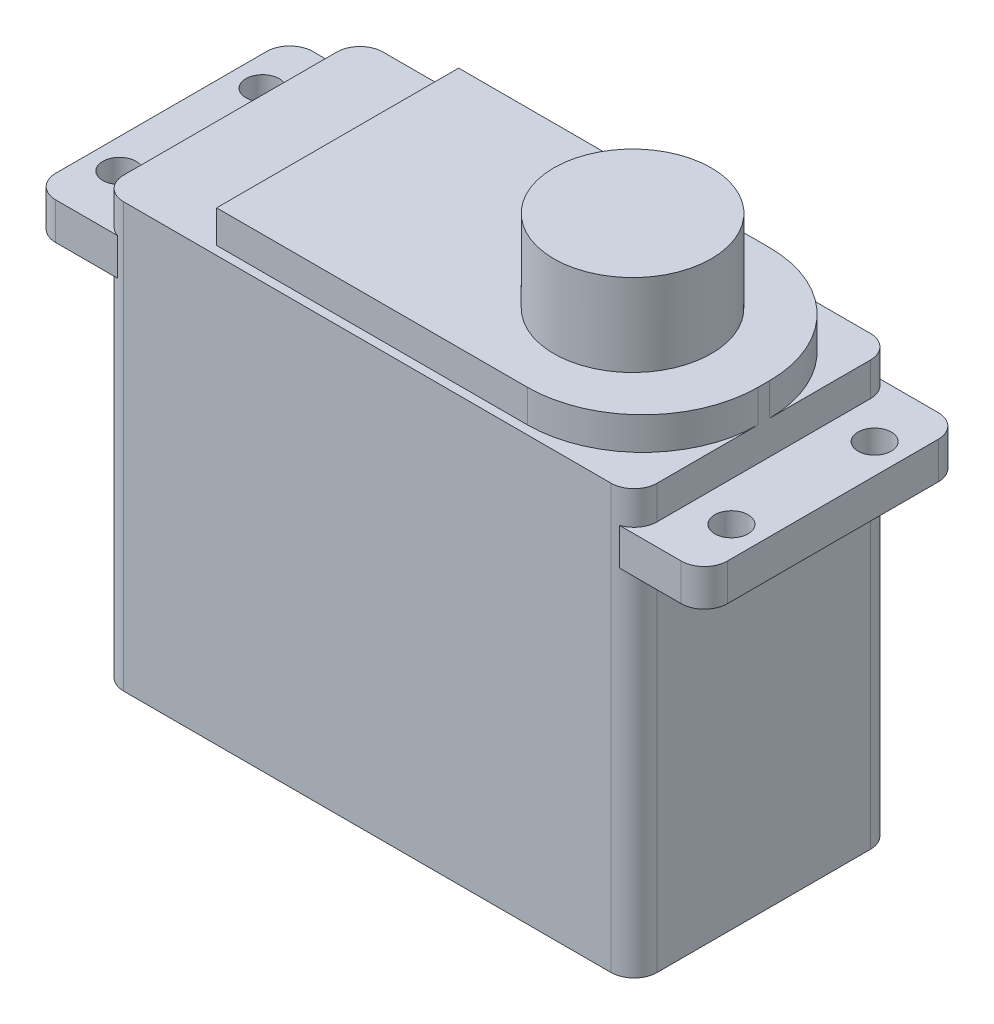
from build123d import *

# Parameters (mm, degrees)
SKETCH1_W           = 58.674
SKETCH1_H           = 28.5242
BOSS_EXTRUDE1_DEPTH = 46.609
SKETCH2_W           = 46.863
SKETCH2_H           = 26.6192
BOSS_EXTRUDE2_DEPTH = 3.5814
FILLET1_R           = 12.7
FILLET2_R           = 2.54
BOSS_EXTRUDE3_START = -7.747
SKETCH3_W           = 73.8632
SKETCH3_H           = 28.2702
BOSS_EXTRUDE3_DEPTH = 4.064
FILLET3_R           = 2.54
SKETCH4_R           = 1.8288
CUT_EXTRUDE1_DEPTH  = 43.926
SKETCH5_R           = 8.6614
BOSS_EXTRUDE4_DEPTH = 12.6238


with BuildPart() as part:
    # Sketch1 → Boss-Extrude1 (new body)
    with BuildSketch(Plane(origin=(0, 0, 0), x_dir=(1, 0, 0), z_dir=(0, 1, 0))):
        Rectangle(SKETCH1_W, SKETCH1_H)
    extrude(amount=BOSS_EXTRUDE1_DEPTH)

    # Sketch2 → Boss-Extrude2 (add)
    with BuildSketch(Plane(origin=(0, 46.609, 0), x_dir=(1, 0, 0), z_dir=(0, 1, 0))):
        with Locations((5.9055, 0)):
            Rectangle(SKETCH2_W, SKETCH2_H)
    extrude(amount=BOSS_EXTRUDE2_DEPTH)

    # Fillet1
    fillet1_edges = [part.edges().sort_by_distance(p)[0] for p in [
        (29.337, 48.3997, 13.3096),
        (29.337, 48.3997, -13.3096),
    ]]
    fillet(fillet1_edges, radius=FILLET1_R)

    # Fillet2
    fillet2_edges = [part.edges().sort_by_distance(p)[0] for p in [
        (29.337, 23.3045, 14.2621),
        (29.337, 23.3045, -14.2621),
        (-29.337, 23.3045, -14.2621),
        (-29.337, 23.3045, 14.2621),
    ]]
    fillet(fillet2_edges, radius=FILLET2_R)

    # Sketch3 → Boss-Extrude3 (add)
    with BuildSketch(Plane(origin=(0, 46.609, 0), x_dir=(1, 0, 0), z_dir=(0, 1, 0)).offset(BOSS_EXTRUDE3_START)):
        Rectangle(SKETCH3_W, SKETCH3_H)
    extrude(amount=BOSS_EXTRUDE3_DEPTH)

    # Fillet3
    fillet3_edges = [part.edges().sort_by_distance(p)[0] for p in [
        (36.9316, 40.894, -14.1351),
        (-36.9316, 40.894, -14.1351),
        (-36.9316, 40.894, 14.1351),
        (36.9316, 40.894, 14.1351),
    ]]
    fillet(fillet3_edges, radius=FILLET3_R)

    # Sketch4 → Cut-Extrude1 (cut, through all)
    with BuildSketch(Plane(origin=(0, 42.926, 0), x_dir=(1, 0, 0), z_dir=(0, 1, 0))):
        with Locations((-33.655, 7.874)):
            Circle(SKETCH4_R)
        with Locations((-33.655, -7.874)):
            Circle(SKETCH4_R)
        with Locations((33.655, -7.874)):
            Circle(SKETCH4_R)
        with Locations((33.655, 7.874)):
            Circle(SKETCH4_R)
    extrude(amount=-CUT_EXTRUDE1_DEPTH, mode=Mode.SUBTRACT)

    # Sketch5 → Boss-Extrude4 (add)
    with BuildSketch(Plane(origin=(0, 46.609, 0), x_dir=(1, 0, 0), z_dir=(0, 1, 0))):
        with Locations((14.9098, 0)):
            Circle(SKETCH5_R)
    extrude(amount=BOSS_EXTRUDE4_DEPTH)


solid = part.part
